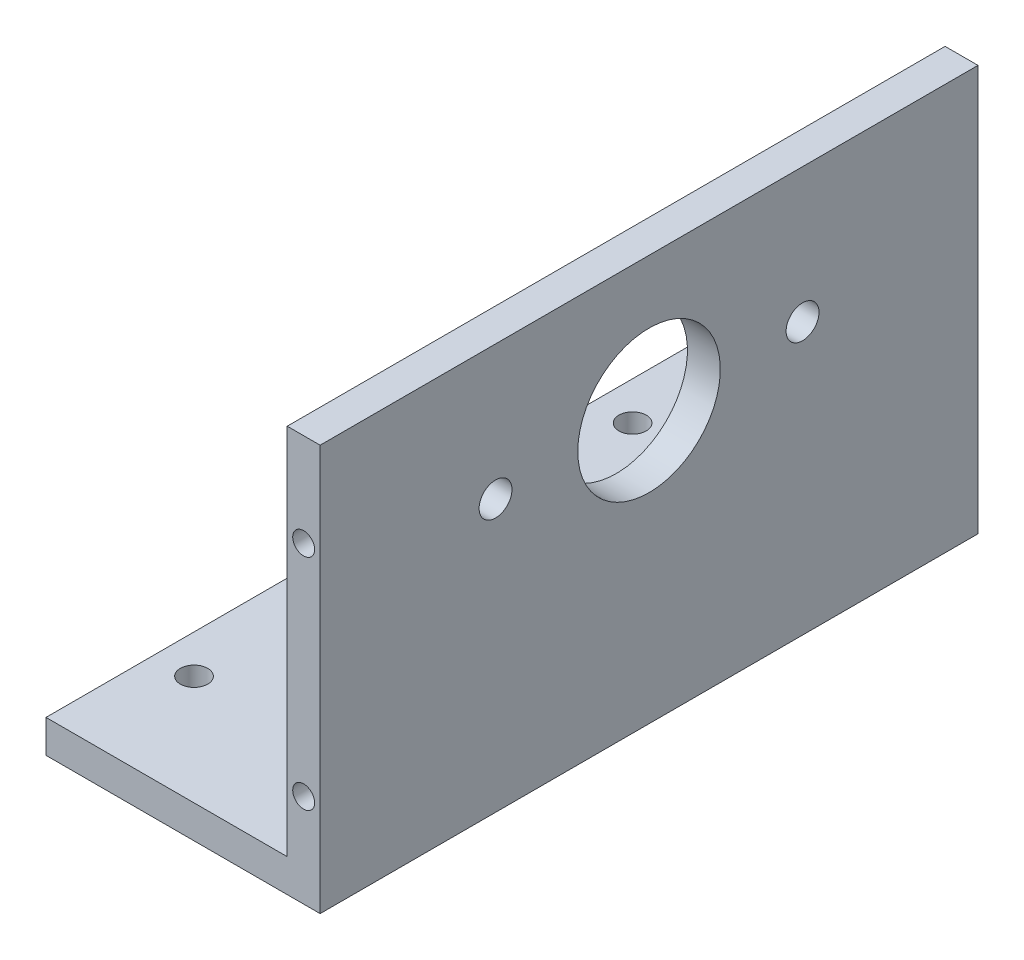
from build123d import *

# Parameters (mm, degrees)
SKETCH_1_W          = 44
SKETCH_1_H          = 120
EXTRUDE_1_DEPTH     = 6
SKETCH_1_3_W        = 6
SKETCH_1_3_H        = 120
EXTRUDE_2_DEPTH     = 74
SKETCH_2_R          = 13
SKETCH_2_R_2        = 3
CUT_EXTRUDE_1_DEPTH = 7
SKETCH_3_R          = 2.5
CUT_EXTRUDE_2_DEPTH = 10
SKETCH_4_R          = 2
CUT_EXTRUDE_3_DEPTH = 20


with BuildPart() as part:
    # Sketch 1 → Extrude 1 (new body)
    with BuildSketch(Plane(origin=(0, 0, 0), x_dir=(1, 0, 0), z_dir=(0, 1, 0))):
        with Locations((-3, 0)):
            Rectangle(SKETCH_1_W, SKETCH_1_H)
    extrude(amount=EXTRUDE_1_DEPTH)

    # Sketch 1_3 → Extrude 2 (add)
    with BuildSketch(Plane(origin=(0, 0, 0), x_dir=(1, 0, 0), z_dir=(0, 1, 0))):
        with Locations((22, 0)):
            Rectangle(SKETCH_1_3_W, SKETCH_1_3_H)
    extrude(amount=EXTRUDE_2_DEPTH)

    # Sketch 2 → Cut-Extrude 1 (cut, through all)
    with BuildSketch(Plane.ZY.offset(-19)):
        with Locations((0, 49.5)):
            Circle(SKETCH_2_R)
        with Locations((-28, 49.5)):
            Circle(SKETCH_2_R_2)
        with Locations((28, 49.5)):
            Circle(SKETCH_2_R_2)
    extrude(amount=-CUT_EXTRUDE_1_DEPTH, mode=Mode.SUBTRACT)

    # Sketch 3 → Cut-Extrude 2 (cut)
    with BuildSketch(Plane(origin=(0, 6, 0), x_dir=(1, 0, 0), z_dir=(0, 1, 0))):
        with Locations((-18, 40)):
            Circle(SKETCH_3_R)
        with Locations((12, 40)):
            Circle(SKETCH_3_R)
        with Locations((-18, -40)):
            Circle(SKETCH_3_R)
        with Locations((12, -40)):
            Circle(SKETCH_3_R)
    extrude(amount=-CUT_EXTRUDE_2_DEPTH, mode=Mode.SUBTRACT)

    # Sketch 4 → Cut-Extrude 3 (cut)
    with BuildSketch(Plane(origin=(0, 0, -60), x_dir=(-1, 0, 0), z_dir=(0, 0, -1))):
        with Locations((-22, 17)):
            Circle(SKETCH_4_R)
        with Locations((-22, 57)):
            Circle(SKETCH_4_R)
    cut_extrude_3 = extrude(amount=-CUT_EXTRUDE_3_DEPTH, mode=Mode.SUBTRACT)

    # Mirror 1: Cut-Extrude 3 across plane
    add(cut_extrude_3.mirror(Plane(origin=(0, 0, 0), x_dir=(1, 0, 0), z_dir=(0, 0, -1))), mode=Mode.SUBTRACT)


solid = part.part
